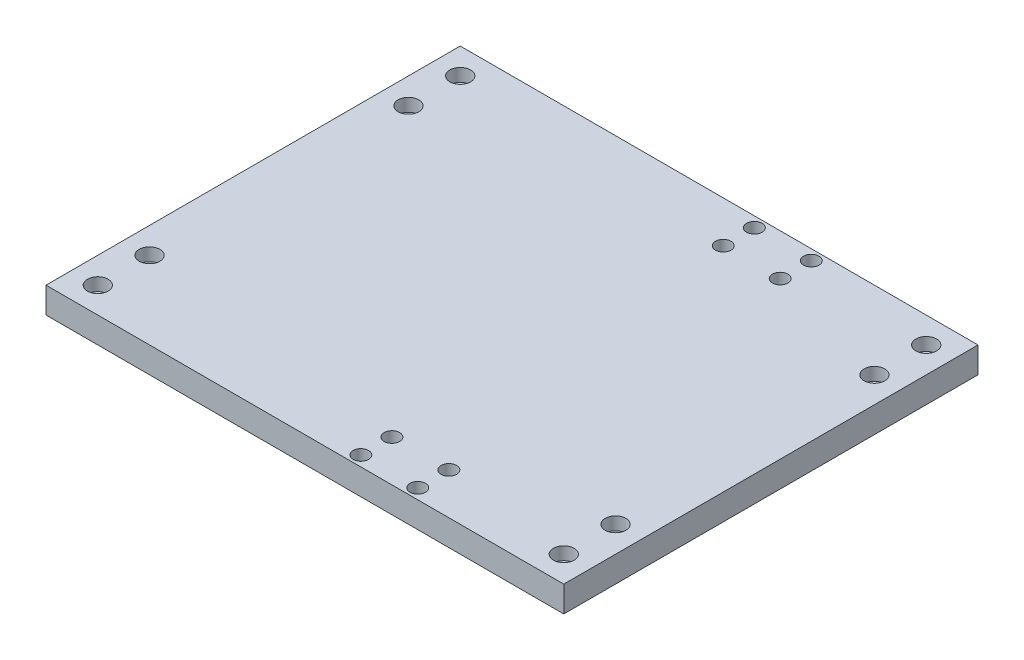
from build123d import *

# Parameters (mm, degrees)
SKETCH1_W               = 100
SKETCH1_H               = 80
SKETCH1_R               = 1
BOSS_EXTRUDE1_DEPTH     = 5
SKETCH2_R               = 2
CUT_EXTRUDE1_DEPTH      = 1
CUT_EXTRUDE1_DEPTH_BACK = 2.5
SKETCH3_R               = 1
CUT_EXTRUDE2_DEPTH      = 6
SKETCH5_R               = 1.5
CUT_EXTRUDE4_DEPTH      = 2.5


with BuildPart() as part:
    # Sketch1 → Boss-Extrude1 (new body)
    with BuildSketch(Plane(origin=(0, 0, 0), x_dir=(1, 0, 0), z_dir=(0, 1, 0))):
        with Locations((50, 40)):
            Rectangle(SKETCH1_W, SKETCH1_H)
        with Locations((95, 75)):
            Circle(SKETCH1_R, mode=Mode.SUBTRACT)
        with Locations((5, 75)):
            Circle(SKETCH1_R, mode=Mode.SUBTRACT)
        with Locations((5, 5)):
            Circle(SKETCH1_R, mode=Mode.SUBTRACT)
        with Locations((95, 5)):
            Circle(SKETCH1_R, mode=Mode.SUBTRACT)
        with Locations((95, 65)):
            Circle(SKETCH1_R, mode=Mode.SUBTRACT)
        with Locations((95, 15)):
            Circle(SKETCH1_R, mode=Mode.SUBTRACT)
        with Locations((5, 15)):
            Circle(SKETCH1_R, mode=Mode.SUBTRACT)
        with Locations((5, 65)):
            Circle(SKETCH1_R, mode=Mode.SUBTRACT)
    extrude(amount=BOSS_EXTRUDE1_DEPTH)

    # Sketch2 → Cut-Extrude1 (cut, two sides)
    with BuildSketch(Plane(origin=(0, 5, 0), x_dir=(1, 0, 0), z_dir=(0, 1, 0))) as cut_extrude1_sk:
        with Locations((5, 75)):
            Circle(SKETCH2_R)
        with Locations((95, 75)):
            Circle(SKETCH2_R)
        with Locations((95, 5)):
            Circle(SKETCH2_R)
        with Locations((5, 5)):
            Circle(SKETCH2_R)
        with Locations((5, 65)):
            Circle(SKETCH2_R)
        with Locations((95, 65)):
            Circle(SKETCH2_R)
        with Locations((95, 15)):
            Circle(SKETCH2_R)
        with Locations((5, 15)):
            Circle(SKETCH2_R)
    extrude(amount=CUT_EXTRUDE1_DEPTH, mode=Mode.SUBTRACT)
    extrude(cut_extrude1_sk.sketch, amount=-CUT_EXTRUDE1_DEPTH_BACK, mode=Mode.SUBTRACT)

    # Sketch3 → Cut-Extrude2 (cut, through all)
    with BuildSketch(Plane(origin=(0, 5, 0), x_dir=(1, 0, 0), z_dir=(0, 1, 0))):
        with Locations((58.8, 8)):
            Circle(SKETCH3_R)
        with Locations((69.8, 8)):
            Circle(SKETCH3_R)
        with Locations((58.8, 2)):
            Circle(SKETCH3_R)
        with Locations((69.8, 2)):
            Circle(SKETCH3_R)
        with Locations((58.8, 78)):
            Circle(SKETCH3_R)
        with Locations((69.8, 72)):
            Circle(SKETCH3_R)
        with Locations((69.8, 78)):
            Circle(SKETCH3_R)
        with Locations((58.8, 72)):
            Circle(SKETCH3_R)
    extrude(amount=-CUT_EXTRUDE2_DEPTH, mode=Mode.SUBTRACT)

    # Sketch5 → Cut-Extrude4 (cut)
    with BuildSketch(Plane(origin=(0, 5, 0), x_dir=(1, 0, 0), z_dir=(0, 1, 0))):
        with Locations((58.8, 8)):
            Circle(SKETCH5_R)
        with Locations((58.8, 2)):
            Circle(SKETCH5_R)
        with Locations((69.8, 2)):
            Circle(SKETCH5_R)
        with Locations((69.8, 8)):
            Circle(SKETCH5_R)
        with Locations((58.8, 78)):
            Circle(SKETCH5_R)
        with Locations((58.8, 72)):
            Circle(SKETCH5_R)
        with Locations((69.8, 72)):
            Circle(SKETCH5_R)
        with Locations((69.8, 78)):
            Circle(SKETCH5_R)
    extrude(amount=-CUT_EXTRUDE4_DEPTH, mode=Mode.SUBTRACT)


solid = part.part
